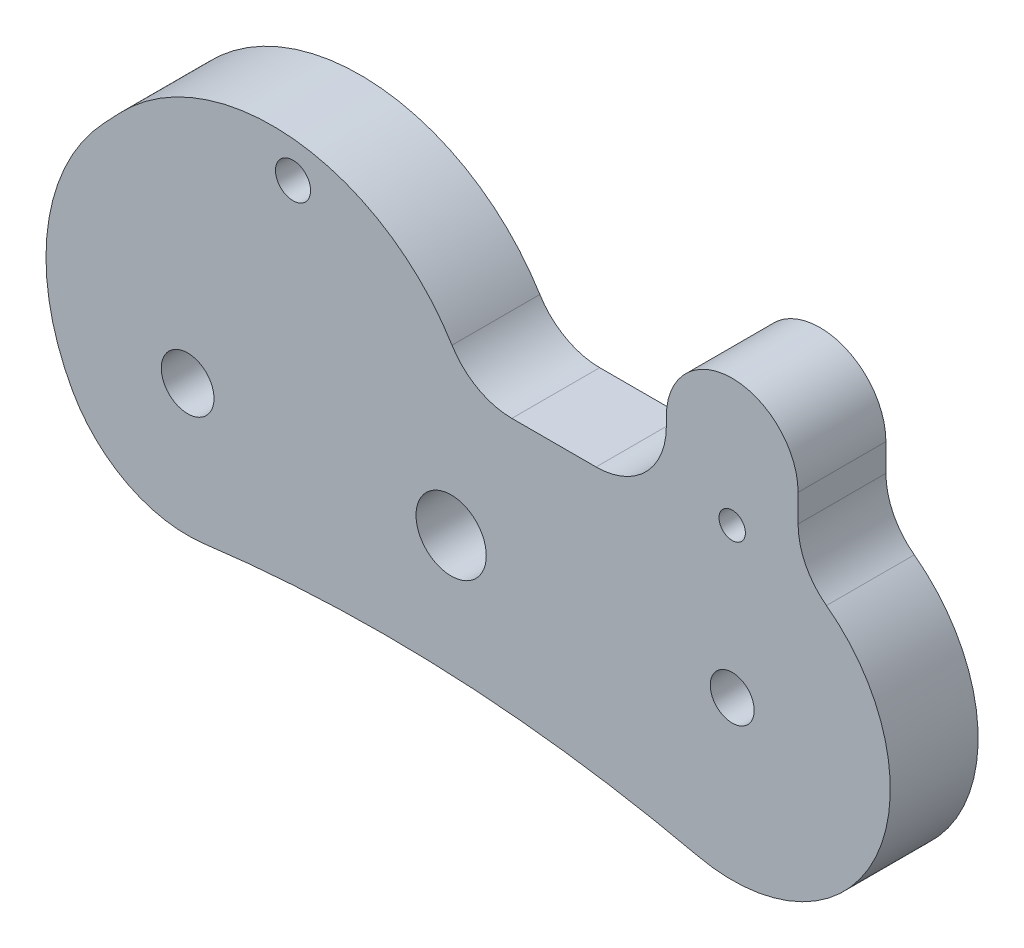
from build123d import *

# Parameters (mm, degrees)
SKETCH1_R           = 1.5
SKETCH1_R_2         = 1.25
SKETCH1_R_3         = 2
SKETCH1_R_4         = 1
SKETCH1_R_5         = 0.75
BOSS_EXTRUDE1_DEPTH = 5


with BuildPart() as part:
    # Sketch1 → Boss-Extrude1 (new body)
    with BuildSketch(Plane.XY):
        with BuildLine():
            Line((18.457499004, 7.5), (23.25, 7.5))
            ThreePointArc((23.25, 7.5), (26.078427125, 8.671572875), (27.25, 11.5))
            Line((27.25, 11.5), (27.25, 12))
            ThreePointArc((27.25, 12), (31, 15.75), (34.75, 12))
            Line((34.75, 12), (34.75, 10.437312873))
            ThreePointArc((34.75, 10.437312873), (35.176593954, 8.639878804), (36.365384615, 7.225831989))
            ThreePointArc((36.365384615, 7.225831989), (39.175605476, -3.762907798), (29.000770207, -8.775139898))
            ThreePointArc((29.000770207, -8.775139898), (15.040769607, -6.867204956), (0.962557604, -7.437975723))
            ThreePointArc((0.962557604, -7.437975723), (-3.385742672, -6.692290083), (-6.5625, -3.630921887))
            ThreePointArc((-6.5625, -3.630921887), (-7.966305911, 3.694931991), (-4.770712178, 10.434886499))
            Line((-4.770712178, 10.434886499), (-3.879663294, 11.374703534))
            ThreePointArc((-3.879663294, 11.374703534), (6.070726491, 15.053905129), (15.050261475, 9.404592542))
            ThreePointArc((15.050261475, 9.404592542), (16.505785633, 8.008465249), (18.457499004, 7.5))
        make_face()
        Circle(SKETCH1_R, mode=Mode.SUBTRACT)
        with Locations((31, 0)):
            Circle(SKETCH1_R_2, mode=Mode.SUBTRACT)
        with Locations((15, 0)):
            Circle(SKETCH1_R_3, mode=Mode.SUBTRACT)
        with Locations((6, 13)):
            Circle(SKETCH1_R_4, mode=Mode.SUBTRACT)
        with Locations((31, 8.5)):
            Circle(SKETCH1_R_5, mode=Mode.SUBTRACT)
    extrude(amount=BOSS_EXTRUDE1_DEPTH)


solid = part.part
